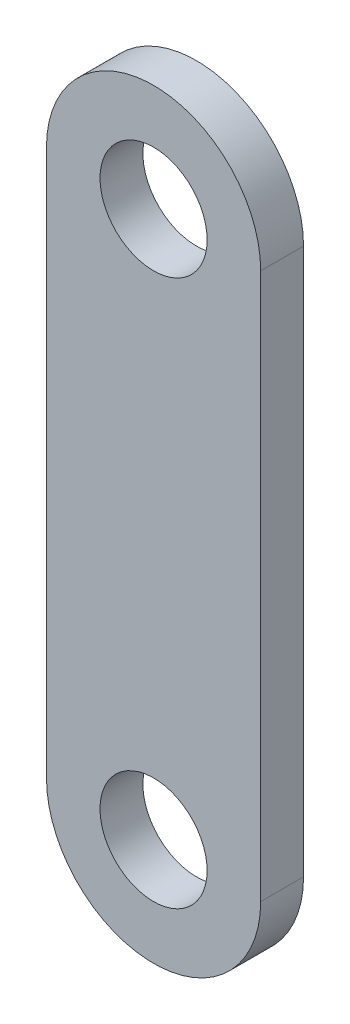
from build123d import *

# Parameters (mm, degrees)
SKETCH1_R           = 25
BOSS_EXTRUDE1_DEPTH = 10


with BuildPart() as part:
    # Sketch1 → Boss-Extrude1 (new body, symmetric)
    with BuildSketch(Plane.XY):
        with BuildLine():
            Line((-50, 127.5), (-50, -127.5))
            ThreePointArc((-50, -127.5), (0, -177.5), (50, -127.5))
            Line((50, -127.5), (50, 127.5))
            ThreePointArc((50, 127.5), (0, 177.5), (-50, 127.5))
        make_face()
        with Locations((0, 127.5)):
            Circle(SKETCH1_R, mode=Mode.SUBTRACT)
        with Locations((0, -127.5)):
            Circle(SKETCH1_R, mode=Mode.SUBTRACT)
    extrude(amount=BOSS_EXTRUDE1_DEPTH, both=True)


solid = part.part
